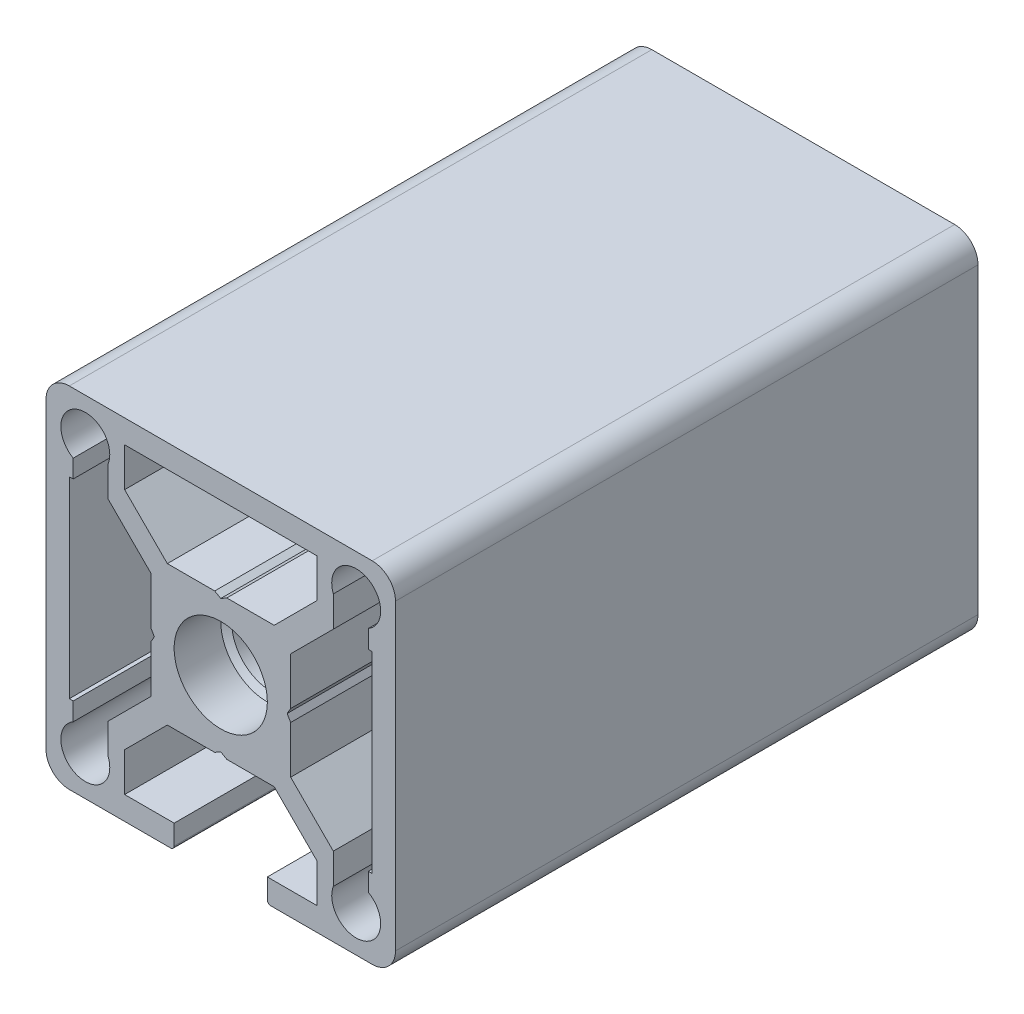
from build123d import *

# Parameters (mm, degrees)
SKETCH1_R           = 2.1
SKETCH1_R_2         = 3.4
BOSS_EXTRUDE1_DEPTH = 50
SKETCH3_W           = 2
SKETCH3_H           = 9.175206629
SKETCH3_W_2         = 11.07645362
SKETCH3_H_2         = 2
SKETCH3_H_3         = 11.915453224
BOSS_EXTRUDE2_DEPTH = 50
SKETCH4_W           = 3
SKETCH4_H           = 21.746320034
CUT_EXTRUDE1_DEPTH  = 51


with BuildPart() as part:
    # Sketch1 → Boss-Extrude1 (new body)
    with BuildSketch(Plane.XY):
        with BuildLine():
            Line((-15, 13), (-15, 4.3))
            ThreePointArc((-15, 4.3), (-14.912132034, 4.087867966), (-14.7, 4))
            Line((-14.7, 4), (-13, 4))
            Line((-13, 4), (-13, 8.25))
            Line((-13, 8.25), (-9.6642, 8.25))
            Line((-9.6642, 8.25), (-6, 4.5858))
            Line((-6, 4.5858), (-6, 0.519615242))
            Line((-6, 0.519615242), (-5.7, 0))
            Line((-5.7, 0), (-6, -0.519615242))
            Line((-6, -0.519615242), (-6, -4.5858))
            Line((-6, -4.5858), (-9.6642, -8.25))
            Line((-9.6642, -8.25), (-13, -8.25))
            Line((-13, -8.25), (-13, -4))
            Line((-13, -4), (-14.7, -4))
            ThreePointArc((-14.7, -4), (-14.912132034, -4.087867966), (-15, -4.3))
            Line((-15, -4.3), (-15, -13))
            ThreePointArc((-15, -13), (-14.414213562, -14.414213562), (-13, -15))
            Line((-13, -15), (-4.3, -15))
            ThreePointArc((-4.3, -15), (-4.087867966, -14.912132034), (-4, -14.7))
            Line((-4, -14.7), (-4, -13))
            Line((-4, -13), (-8.25, -13))
            Line((-8.25, -13), (-8.25, -9.6642))
            Line((-8.25, -9.6642), (-4.5858, -6))
            Line((-4.5858, -6), (-0.519615242, -6))
            Line((-0.519615242, -6), (0, -5.7))
            Line((0, -5.7), (0.519615242, -6))
            Line((0.519615242, -6), (4.5858, -6))
            Line((4.5858, -6), (8.25, -9.6642))
            Line((8.25, -9.6642), (8.25, -13))
            Line((8.25, -13), (4, -13))
            Line((4, -13), (4, -14.7))
            ThreePointArc((4, -14.7), (4.087867966, -14.912132034), (4.3, -15))
            Line((4.3, -15), (13, -15))
            ThreePointArc((13, -15), (14.414213562, -14.414213562), (15, -13))
            Line((15, -13), (15, -4.3))
            ThreePointArc((15, -4.3), (14.912132034, -4.087867966), (14.7, -4))
            Line((14.7, -4), (13, -4))
            Line((13, -4), (13, -8.25))
            Line((13, -8.25), (9.6642, -8.25))
            Line((9.6642, -8.25), (6, -4.5858))
            Line((6, -4.5858), (6, -0.519615242))
            Line((6, -0.519615242), (5.7, 0))
            Line((5.7, 0), (6, 0.519615242))
            Line((6, 0.519615242), (6, 4.5858))
            Line((6, 4.5858), (9.6642, 8.25))
            Line((9.6642, 8.25), (13, 8.25))
            Line((13, 8.25), (13, 4))
            Line((13, 4), (14.7, 4))
            ThreePointArc((14.7, 4), (14.912132034, 4.087867966), (15, 4.3))
            Line((15, 4.3), (15, 13))
            ThreePointArc((15, 13), (14.414213562, 14.414213562), (13, 15))
            Line((13, 15), (4.3, 15))
            ThreePointArc((4.3, 15), (4.087867966, 14.912132034), (4, 14.7))
            Line((4, 14.7), (4, 13))
            Line((4, 13), (8.25, 13))
            Line((8.25, 13), (8.25, 9.6642))
            Line((8.25, 9.6642), (4.5858, 6))
            Line((4.5858, 6), (0.519615242, 6))
            Line((0.519615242, 6), (0, 5.7))
            Line((0, 5.7), (-0.519615242, 6))
            Line((-0.519615242, 6), (-4.5858, 6))
            Line((-4.5858, 6), (-8.25, 9.6642))
            Line((-8.25, 9.6642), (-8.25, 13))
            Line((-8.25, 13), (-4, 13))
            Line((-4, 13), (-4, 14.7))
            ThreePointArc((-4, 14.7), (-4.087867966, 14.912132034), (-4.3, 15))
            Line((-4.3, 15), (-13, 15))
            ThreePointArc((-13, 15), (-14.414213562, 14.414213562), (-15, 13))
        make_face()
        with Locations((11.625, -11.625)):
            Circle(SKETCH1_R, mode=Mode.SUBTRACT)
        with Locations((11.625, 11.625)):
            Circle(SKETCH1_R, mode=Mode.SUBTRACT)
        Circle(SKETCH1_R_2, mode=Mode.SUBTRACT)
        with Locations((-11.625, -11.625)):
            Circle(SKETCH1_R, mode=Mode.SUBTRACT)
        with Locations((-11.625, 11.625)):
            Circle(SKETCH1_R, mode=Mode.SUBTRACT)
    extrude(amount=-BOSS_EXTRUDE1_DEPTH)

    # Sketch2 → Cut-Revolve1 (revolve, cut)
    with BuildSketch(Plane(origin=(0, 0, 0), x_dir=(-1, 0, 0), z_dir=(0, 1, 0))):
        Polygon((0, -28.31882362), (-3.3235, -26.4), (-3.3235, -0.6765), (-4, 0), (0, 0), align=None)
    revolve(axis=Axis((0, 0, 0), (0, 0, -1)), mode=Mode.SUBTRACT)

    # Sketch3 → Boss-Extrude2 (add)
    with BuildSketch(Plane.XY):
        with Locations((-14, -0.287603314)):
            Rectangle(SKETCH3_W, SKETCH3_H)
        with Locations((-0.643781897, 14)):
            Rectangle(SKETCH3_W_2, SKETCH3_H_2)
        with Locations((14, -0.392977161)):
            Rectangle(SKETCH3_W, SKETCH3_H_3)
    extrude(amount=-BOSS_EXTRUDE2_DEPTH)

    # Sketch4 → Cut-Extrude1 (cut, through all)
    with BuildSketch(Plane.XY):
        with Locations((11.1642, 0)):
            Rectangle(SKETCH4_W, SKETCH4_H)
        with Locations((-11.1642, 0)):
            Rectangle(SKETCH4_W, SKETCH4_H)
    extrude(amount=-CUT_EXTRUDE1_DEPTH, mode=Mode.SUBTRACT)

    # Sketch5 → Cut-Revolve5 (revolve, cut)
    with BuildSketch(Plane(origin=(0, 0, 0), x_dir=(0, 0, -1), z_dir=(1, 0, 0))):
        Polygon((0, 0), (0, 4), (4, 4), (6.309401077, 0), align=None)
    revolve(axis=Axis((0, 0, 0), (0, 0, -1)), mode=Mode.SUBTRACT)


solid = part.part
